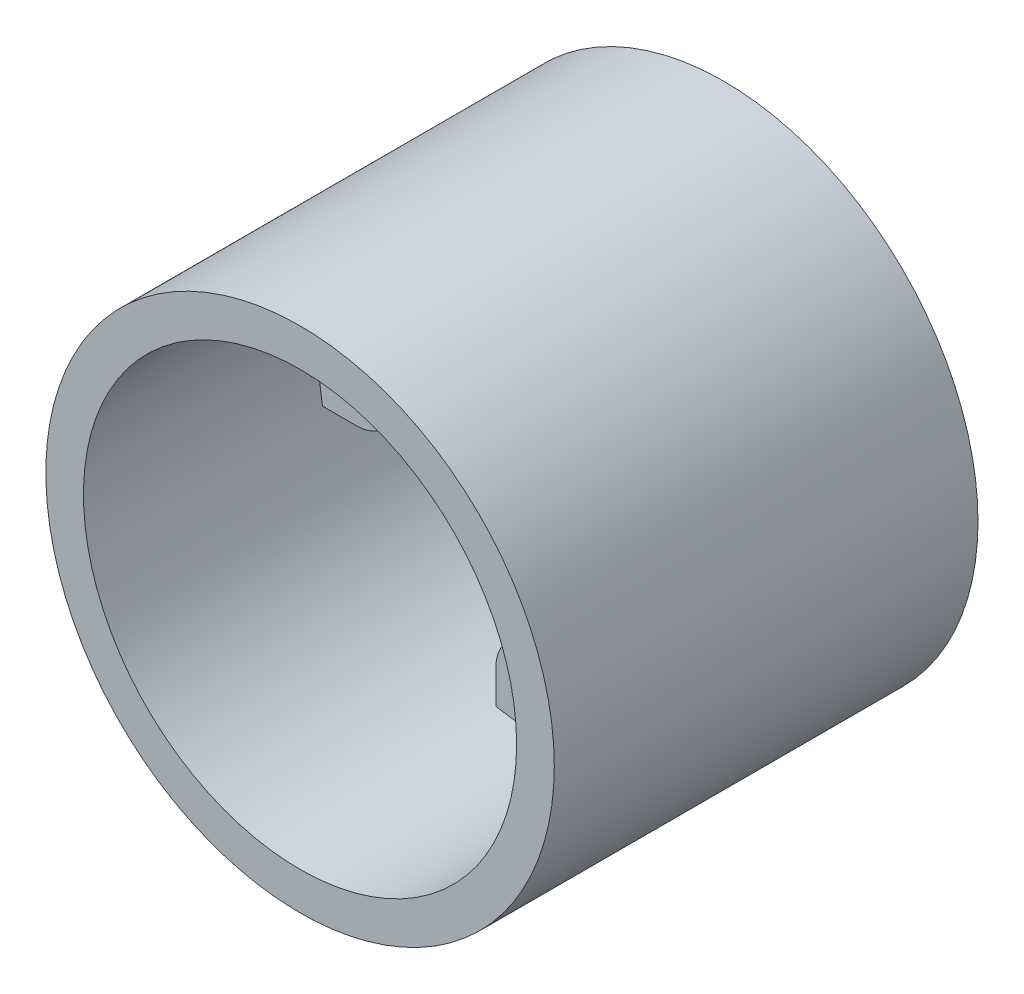
from build123d import *

# Parameters (mm, degrees)
SKETCH1_R           = 27
BOSS_EXTRUDE1_DEPTH = 45
SKETCH1_3_R         = 1.7
BOSS_EXTRUDE2_DEPTH = 20


with BuildPart() as part:
    # Sketch1 → Boss-Extrude1 (new body)
    with BuildSketch(Plane.XY):
        Circle(SKETCH1_R)
        with BuildLine():
            ThreePointArc((-22.61327044, 4.2), (-16.263455967, 16.263455967), (-4.2, 22.61327044))
            ThreePointArc((-4.2, 22.61327044), (0, 23), (4.2, 22.61327044))
            ThreePointArc((4.2, 22.61327044), (16.263455967, 16.263455967), (22.61327044, 4.2))
            ThreePointArc((22.61327044, 4.2), (22.903113545, 2.108883576), (23, 0))
            ThreePointArc((23, 0), (22.903113545, -2.108883576), (22.61327044, -4.2))
            ThreePointArc((22.61327044, -4.2), (16.263455967, -16.263455967), (4.2, -22.61327044))
            ThreePointArc((4.2, -22.61327044), (0, -23), (-4.2, -22.61327044))
            ThreePointArc((-4.2, -22.61327044), (-16.263455967, -16.263455967), (-22.61327044, -4.2))
            ThreePointArc((-22.61327044, -4.2), (-23, 0), (-22.61327044, 4.2))
        make_face(mode=Mode.SUBTRACT)
    extrude(amount=BOSS_EXTRUDE1_DEPTH)

    # Sketch1_3 → Boss-Extrude2 (add)
    # profile 1 of 4: a face of its own
    with BuildSketch(Plane.XY):
        with BuildLine():
            Line((-4.2, 22.61327044), (-4.2, 19))
            ThreePointArc((-4.2, 19), (0, 14.8), (4.2, 19))
            Line((4.2, 19), (4.2, 22.61327044))
            ThreePointArc((4.2, 22.61327044), (0, 23), (-4.2, 22.61327044))
        make_face()
        with Locations((0, 19)):
            Circle(SKETCH1_3_R, mode=Mode.SUBTRACT)
    # profile 2 of 4: a face of its own
    with BuildSketch(Plane.XY):
        with BuildLine():
            Line((-19, 4.2), (-22.61327044, 4.2))
            ThreePointArc((-22.61327044, 4.2), (-23, 0), (-22.61327044, -4.2))
            Line((-22.61327044, -4.2), (-19, -4.2))
            ThreePointArc((-19, -4.2), (-14.8, 0), (-19, 4.2))
        make_face()
        with Locations((-19, 0)):
            Circle(SKETCH1_3_R, mode=Mode.SUBTRACT)
    # profile 3 of 4: a face of its own
    with BuildSketch(Plane.XY):
        with BuildLine():
            ThreePointArc((22.61327044, -4.2), (23, 0), (22.61327044, 4.2))
            Line((22.61327044, 4.2), (19, 4.2))
            ThreePointArc((19, 4.2), (14.8, 0), (19, -4.2))
            Line((19, -4.2), (22.61327044, -4.2))
        make_face()
        with Locations((19, 0)):
            Circle(SKETCH1_3_R, mode=Mode.SUBTRACT)
    # profile 4 of 4: a face of its own
    with BuildSketch(Plane.XY):
        with BuildLine():
            Line((-4.2, -19), (-4.2, -22.61327044))
            ThreePointArc((-4.2, -22.61327044), (0, -23), (4.2, -22.61327044))
            Line((4.2, -22.61327044), (4.2, -19))
            ThreePointArc((4.2, -19), (0, -14.8), (-4.2, -19))
        make_face()
        with Locations((0, -19)):
            Circle(SKETCH1_3_R, mode=Mode.SUBTRACT)
    extrude(amount=BOSS_EXTRUDE2_DEPTH)


solid = part.part
